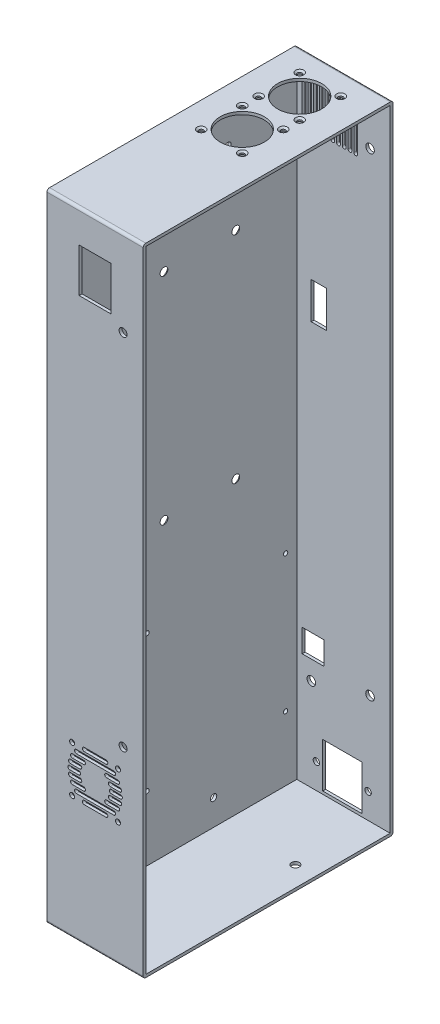
from build123d import *

# Parameters (mm, degrees)
SKETCH1_W                                         = 174
SKETCH1_H                                         = 443
BOSS_EXTRUDE1_DEPTH                               = 2
SKETCH2_W                                         = 174
SKETCH2_H                                         = 443
SKETCH2_W_2                                       = 170
SKETCH2_H_2                                       = 439
BOSS_EXTRUDE2_DEPTH                               = 65
FILLET1_R                                         = 1.8
SKETCH4_R                                         = 1.75
SKETCH4_R_2                                       = 2.75
SKETCH4_W                                         = 22.15
SKETCH4_H                                         = 30.5
CUT_EXTRUDE1_DEPTH                                = 5
SKETCH5_R                                         = 2.25
SKETCH5_R_2                                       = 3
SKETCH5_W                                         = 27.3
SKETCH5_H                                         = 31.1
SKETCH5_W_2                                       = 15.303
SKETCH5_H_2                                       = 16
SKETCH5_W_3                                       = 10.5
SKETCH5_H_3                                       = 25.5
CUT_EXTRUDE2_DEPTH                                = 5
SKETCH11_R                                        = 1.5
SKETCH11_R_2                                      = 2.25
CUT_EXTRUDE4_DEPTH                                = 5
CSK_FOR_M4_FLAT_HEAD_MACHINE_SCREW1_D             = 4.5
CSK_FOR_M4_FLAT_HEAD_MACHINE_SCREW1_DEPTH         = 10
CSK_FOR_M4_FLAT_HEAD_MACHINE_SCREW1_CSINK_D       = 9.4
CSK_FOR_M4_FLAT_HEAD_MACHINE_SCREW1_CSINK_ANGLE   = 90
CSK_FOR_M4_FLAT_HEAD_MACHINE_SCREW1_TIP           = 1.351936393
SKETCH14_R                                        = 15.365
SKETCH14_R_2                                      = 1.5
CUT_EXTRUDE5_DEPTH                                = 10
CSK_FOR_4_FLAT_HEAD_MACHINE_SCREW_100_D           = 3.2639
CSK_FOR_4_FLAT_HEAD_MACHINE_SCREW_100_DEPTH       = 10
CSK_FOR_4_FLAT_HEAD_MACHINE_SCREW_100_CSINK_D     = 5.715
CSK_FOR_4_FLAT_HEAD_MACHINE_SCREW_100_CSINK_ANGLE = 100
CSK_FOR_4_FLAT_HEAD_MACHINE_SCREW_100_TIP         = 0.980574487
SKETCH17_R                                        = 2.75
CUT_EXTRUDE6_DEPTH                                = 10


with BuildPart() as part:
    # Sketch1 → Boss-Extrude1 (new body)
    with BuildSketch(Plane(origin=(0, 0, 0), x_dir=(0, 0, -1), z_dir=(1, 0, 0))):
        Rectangle(SKETCH1_W, SKETCH1_H)
    extrude(amount=BOSS_EXTRUDE1_DEPTH)

    # Sketch2 → Boss-Extrude2 (add)
    with BuildSketch(Plane(origin=(2, 0, 0), x_dir=(0, 0, -1), z_dir=(1, 0, 0))):
        Rectangle(SKETCH2_W, SKETCH2_H)
        Rectangle(SKETCH2_W_2, SKETCH2_H_2, mode=Mode.SUBTRACT)
    extrude(amount=BOSS_EXTRUDE2_DEPTH)

    # Fillet1
    fillet1_edges = [part.edges().sort_by_distance(p)[0] for p in [
        (33.5, 221.5, 87),
        (33.5, 221.5, -87),
        (33.5, -221.5, -87),
        (33.5, -221.5, 87),
    ]]
    fillet(fillet1_edges, radius=FILLET1_R)

    # Sketch4 → Cut-Extrude1 (cut)
    with BuildSketch(Plane.XY.offset(87)):
        with Locations((17.5, -135.5)):
            Circle(SKETCH4_R)
        with Locations((49.5, -135.5)):
            Circle(SKETCH4_R)
        with Locations((17.5, -103.5)):
            Circle(SKETCH4_R)
        with Locations((49.5, -103.5)):
            Circle(SKETCH4_R)
        with Locations((53, -88.5)):
            Circle(SKETCH4_R_2)
        with Locations((53, 161.5)):
            Circle(SKETCH4_R_2)
        with Locations((33.5, 183.75)):
            Rectangle(SKETCH4_W, SKETCH4_H)
        with BuildLine():
            Line((15.8, -118.2), (22.2, -118.2))
            ThreePointArc((22.2, -118.2), (23.5, -119.5), (22.2, -120.8))
            Line((22.2, -120.8), (15.8, -120.8))
            ThreePointArc((15.8, -120.8), (14.5, -119.5), (15.8, -118.2))
        make_face()
        with BuildLine():
            Line((16.25790036, -114.2), (22.931651028, -114.2))
            ThreePointArc((22.931651028, -114.2), (24.231651028, -115.5), (22.931651028, -116.8))
            Line((22.931651028, -116.8), (16.25790036, -116.8))
            ThreePointArc((16.25790036, -116.8), (14.95790036, -115.5), (16.25790036, -114.2))
        make_face()
        with BuildLine():
            Line((17.711079834, -110.2), (25.519398519, -110.2))
            ThreePointArc((25.519398519, -110.2), (26.819398519, -111.5), (25.519398519, -112.8))
            Line((25.519398519, -112.8), (17.711079834, -112.8))
            ThreePointArc((17.711079834, -112.8), (16.411079834, -111.5), (17.711079834, -110.2))
        make_face()
        with BuildLine():
            Line((20.488850935, -106.2), (46.511149065, -106.2))
            ThreePointArc((46.511149065, -106.2), (47.811149065, -107.5), (46.511149065, -108.8))
            Line((46.511149065, -108.8), (20.488850935, -108.8))
            ThreePointArc((20.488850935, -108.8), (19.188850935, -107.5), (20.488850935, -106.2))
        make_face()
        with BuildLine():
            Line((25.930984212, -102.2), (41.069015788, -102.2))
            ThreePointArc((41.069015788, -102.2), (42.369015788, -103.5), (41.069015788, -104.8))
            Line((41.069015788, -104.8), (25.930984212, -104.8))
            ThreePointArc((25.930984212, -104.8), (24.630984212, -103.5), (25.930984212, -102.2))
        make_face()
        with BuildLine():
            Line((16.25790036, -122.2), (22.931651028, -122.2))
            ThreePointArc((22.931651028, -122.2), (24.231651028, -123.5), (22.931651028, -124.8))
            Line((22.931651028, -124.8), (16.25790036, -124.8))
            ThreePointArc((16.25790036, -124.8), (14.95790036, -123.5), (16.25790036, -122.2))
        make_face()
        with BuildLine():
            Line((17.711079834, -126.2), (25.519398519, -126.2))
            ThreePointArc((25.519398519, -126.2), (26.819398519, -127.5), (25.519398519, -128.8))
            Line((25.519398519, -128.8), (17.711079834, -128.8))
            ThreePointArc((17.711079834, -128.8), (16.411079834, -127.5), (17.711079834, -126.2))
        make_face()
        with BuildLine():
            Line((41.480601481, -110.2), (49.288920166, -110.2))
            ThreePointArc((49.288920166, -110.2), (50.588920166, -111.5), (49.288920166, -112.8))
            Line((49.288920166, -112.8), (41.480601481, -112.8))
            ThreePointArc((41.480601481, -112.8), (40.180601481, -111.5), (41.480601481, -110.2))
        make_face()
        with BuildLine():
            Line((44.068348972, -114.2), (50.74209964, -114.2))
            ThreePointArc((50.74209964, -114.2), (52.04209964, -115.5), (50.74209964, -116.8))
            Line((50.74209964, -116.8), (44.068348972, -116.8))
            ThreePointArc((44.068348972, -116.8), (42.768348972, -115.5), (44.068348972, -114.2))
        make_face()
        with BuildLine():
            Line((44.8, -118.2), (51.2, -118.2))
            ThreePointArc((51.2, -118.2), (52.5, -119.5), (51.2, -120.8))
            Line((51.2, -120.8), (44.8, -120.8))
            ThreePointArc((44.8, -120.8), (43.5, -119.5), (44.8, -118.2))
        make_face()
        with BuildLine():
            Line((44.068348972, -122.2), (50.74209964, -122.2))
            ThreePointArc((50.74209964, -122.2), (52.04209964, -123.5), (50.74209964, -124.8))
            Line((50.74209964, -124.8), (44.068348972, -124.8))
            ThreePointArc((44.068348972, -124.8), (42.768348972, -123.5), (44.068348972, -122.2))
        make_face()
        with BuildLine():
            Line((41.480601481, -126.2), (49.288920166, -126.2))
            ThreePointArc((49.288920166, -126.2), (50.588920166, -127.5), (49.288920166, -128.8))
            Line((49.288920166, -128.8), (41.480601481, -128.8))
            ThreePointArc((41.480601481, -128.8), (40.180601481, -127.5), (41.480601481, -126.2))
        make_face()
        with BuildLine():
            Line((20.488850935, -130.2), (46.511149065, -130.2))
            ThreePointArc((46.511149065, -130.2), (47.811149065, -131.5), (46.511149065, -132.8))
            Line((46.511149065, -132.8), (20.488850935, -132.8))
            ThreePointArc((20.488850935, -132.8), (19.188850935, -131.5), (20.488850935, -130.2))
        make_face()
        with BuildLine():
            Line((25.930984212, -134.2), (41.069015788, -134.2))
            ThreePointArc((41.069015788, -134.2), (42.369015788, -135.5), (41.069015788, -136.8))
            Line((41.069015788, -136.8), (25.930984212, -136.8))
            ThreePointArc((25.930984212, -136.8), (24.630984212, -135.5), (25.930984212, -134.2))
        make_face()
    extrude(amount=-CUT_EXTRUDE1_DEPTH, mode=Mode.SUBTRACT)

    # Sketch5 → Cut-Extrude2 (cut)
    with BuildSketch(Plane(origin=(0, 0, -87), x_dir=(-1, 0, 0), z_dir=(0, 0, -1))):
        with Locations(Location((-51.65, -201.95, 0), (0, 0, 90))):  # turned: the seam where the file's is
            Circle(SKETCH5_R)
        with Locations(Location((-15.65, -201.95, 0), (0, 0, 90))):  # turned: the seam where the file's is
            Circle(SKETCH5_R)
        with Locations(Location((-12.096, -155.07, 0), (0, 0, 90))):  # turned: the seam where the file's is
            Circle(SKETCH5_R_2)
        with Locations(Location((-53, 186.5, 0), (0, 0, 90))):  # turned: the seam where the file's is
            Circle(SKETCH5_R_2)
        with Locations(Location((-53, -143.5, 0), (0, 0, 90))):  # turned: the seam where the file's is
            Circle(SKETCH5_R_2)
        with Locations((-33.65, -201.95)):
            Rectangle(SKETCH5_W, SKETCH5_H)
        with Locations((-13.4295, -133.89)):
            Rectangle(SKETCH5_W_2, SKETCH5_H_2)
        with Locations((-17.25, 74.25)):
            Rectangle(SKETCH5_W_3, SKETCH5_H_3)
        with BuildLine():
            Line((-41.7, 213.5), (-41.7, 178.5))
            ThreePointArc((-41.7, 178.5), (-43, 177.2), (-44.3, 178.5))
            Line((-44.3, 178.5), (-44.3, 213.5))
            ThreePointArc((-44.3, 213.5), (-43, 214.8), (-41.7, 213.5))
        make_face()
        with BuildLine():
            Line((-33.7, 213.5), (-33.7, 178.5))
            ThreePointArc((-33.7, 178.5), (-35, 177.2), (-36.3, 178.5))
            Line((-36.3, 178.5), (-36.3, 213.5))
            ThreePointArc((-36.3, 213.5), (-35, 214.8), (-33.7, 213.5))
        make_face()
        with BuildLine():
            Line((-37.7, 213.5), (-37.7, 178.5))
            ThreePointArc((-37.7, 178.5), (-39, 177.2), (-40.3, 178.5))
            Line((-40.3, 178.5), (-40.3, 213.5))
            ThreePointArc((-40.3, 213.5), (-39, 214.8), (-37.7, 213.5))
        make_face()
        with BuildLine():
            Line((-29.7, 213.5), (-29.7, 178.5))
            ThreePointArc((-29.7, 178.5), (-31, 177.2), (-32.3, 178.5))
            Line((-32.3, 178.5), (-32.3, 213.5))
            ThreePointArc((-32.3, 213.5), (-31, 214.8), (-29.7, 213.5))
        make_face()
        with BuildLine():
            Line((-25.7, 213.5), (-25.7, 178.5))
            ThreePointArc((-25.7, 178.5), (-27, 177.2), (-28.3, 178.5))
            Line((-28.3, 178.5), (-28.3, 213.5))
            ThreePointArc((-28.3, 213.5), (-27, 214.8), (-25.7, 213.5))
        make_face()
        with BuildLine():
            Line((-21.7, 213.5), (-21.7, 178.5))
            ThreePointArc((-21.7, 178.5), (-23, 177.2), (-24.3, 178.5))
            Line((-24.3, 178.5), (-24.3, 213.5))
            ThreePointArc((-24.3, 213.5), (-23, 214.8), (-21.7, 213.5))
        make_face()
        with BuildLine():
            Line((-13.7, 213.5), (-13.7, 178.5))
            ThreePointArc((-13.7, 178.5), (-15, 177.2), (-16.3, 178.5))
            Line((-16.3, 178.5), (-16.3, 213.5))
            ThreePointArc((-16.3, 213.5), (-15, 214.8), (-13.7, 213.5))
        make_face()
        with BuildLine():
            Line((-5.7, 213.5), (-5.7, 178.5))
            ThreePointArc((-5.7, 178.5), (-7, 177.2), (-8.3, 178.5))
            Line((-8.3, 178.5), (-8.3, 213.5))
            ThreePointArc((-8.3, 213.5), (-7, 214.8), (-5.7, 213.5))
        make_face()
        with BuildLine():
            Line((-17.7, 213.5), (-17.7, 178.5))
            ThreePointArc((-17.7, 178.5), (-19, 177.2), (-20.3, 178.5))
            Line((-20.3, 178.5), (-20.3, 213.5))
            ThreePointArc((-20.3, 213.5), (-19, 214.8), (-17.7, 213.5))
        make_face()
        with BuildLine():
            Line((-9.7, 213.5), (-9.7, 178.5))
            ThreePointArc((-9.7, 178.5), (-11, 177.2), (-12.3, 178.5))
            Line((-12.3, 178.5), (-12.3, 213.5))
            ThreePointArc((-12.3, 213.5), (-11, 214.8), (-9.7, 213.5))
        make_face()
    extrude(amount=-CUT_EXTRUDE2_DEPTH, mode=Mode.SUBTRACT)

    # Sketch11 → Cut-Extrude4 (cut)
    with BuildSketch(Plane(origin=(2, 0, 0), x_dir=(0, 0, -1), z_dir=(1, 0, 0))):
        with Locations((-19.33, -79.31)):
            Circle(SKETCH11_R)
        with Locations((77.19, -79.31)):
            Circle(SKETCH11_R)
        with Locations((-19.33, -174.56)):
            Circle(SKETCH11_R)
        with Locations((77.19, -174.56)):
            Circle(SKETCH11_R)
        with Locations((-7.5, 133)):
            Circle(SKETCH11_R)
        with Locations((42.5, 133)):
            Circle(SKETCH11_R)
        with Locations((42.5, -17)):
            Circle(SKETCH11_R)
        with Locations((-7.5, -17)):
            Circle(SKETCH11_R)
        with Locations((27, -201.5)):
            Circle(SKETCH11_R_2)
        with Locations((37, 186.5)):
            Circle(SKETCH11_R_2)
    extrude(amount=-CUT_EXTRUDE4_DEPTH, mode=Mode.SUBTRACT)

    # CSK for M4 Flat Head Machine Screw1
    with Locations(Plane.ZY):
        with Locations((-42.5, 133), (7.5, 133), (7.5, -17), (-42.5, -17)):
            CounterSinkHole(CSK_FOR_M4_FLAT_HEAD_MACHINE_SCREW1_D / 2, CSK_FOR_M4_FLAT_HEAD_MACHINE_SCREW1_CSINK_D / 2, depth=CSK_FOR_M4_FLAT_HEAD_MACHINE_SCREW1_DEPTH, counter_sink_angle=CSK_FOR_M4_FLAT_HEAD_MACHINE_SCREW1_CSINK_ANGLE)
            with Locations((0, 0, -(CSK_FOR_M4_FLAT_HEAD_MACHINE_SCREW1_DEPTH + CSK_FOR_M4_FLAT_HEAD_MACHINE_SCREW1_TIP / 2))):  # 118° drill point
                Cone(0, CSK_FOR_M4_FLAT_HEAD_MACHINE_SCREW1_D / 2, CSK_FOR_M4_FLAT_HEAD_MACHINE_SCREW1_TIP, mode=Mode.SUBTRACT)

    # Sketch14 → Cut-Extrude5 (cut)
    with BuildSketch(Plane(origin=(0, 221.5, 0), x_dir=(1, 0, 0), z_dir=(0, 1, 0))):
        with Locations(Location((32, 57, 0), (0, 0, 270))):  # turned: the seam where the file's is
            Circle(SKETCH14_R)
        with Locations(Location((17.71, 71.29, 0), (0, 0, 270))):  # turned: the seam where the file's is
            Circle(SKETCH14_R_2)
        with Locations(Location((46.29, 71.29, 0), (0, 0, 270))):  # turned: the seam where the file's is
            Circle(SKETCH14_R_2)
        with Locations(Location((46.29, 42.71, 0), (0, 0, 270))):  # turned: the seam where the file's is
            Circle(SKETCH14_R_2)
        with Locations(Location((17.71, 42.71, 0), (0, 0, 270))):  # turned: the seam where the file's is
            Circle(SKETCH14_R_2)
        with Locations(Location((32, 17, 0), (0, 0, 270))):  # turned: the seam where the file's is
            Circle(SKETCH14_R)
        with Locations(Location((17.71, 31.29, 0), (0, 0, 270))):  # turned: the seam where the file's is
            Circle(SKETCH14_R_2)
        with Locations(Location((46.29, 31.29, 0), (0, 0, 270))):  # turned: the seam where the file's is
            Circle(SKETCH14_R_2)
        with Locations(Location((46.29, 2.71, 0), (0, 0, 270))):  # turned: the seam where the file's is
            Circle(SKETCH14_R_2)
        with Locations(Location((17.71, 2.71, 0), (0, 0, 270))):  # turned: the seam where the file's is
            Circle(SKETCH14_R_2)
    extrude(amount=-CUT_EXTRUDE5_DEPTH, mode=Mode.SUBTRACT)

    # CSK for #4 Flat Head Machine Screw (100)1
    with Locations(Plane(origin=(0, 221.5, 0), x_dir=(-1, 0, 0), z_dir=(0, 1, 0))):
        with Locations((-17.71, -71.29), (-17.71, -42.71), (-46.29, -42.71), (-46.29, -71.29), (-17.71, -31.29), (-46.29, -31.29), (-46.29, -2.71), (-17.71, -2.71)):
            CounterSinkHole(CSK_FOR_4_FLAT_HEAD_MACHINE_SCREW_100_D / 2, CSK_FOR_4_FLAT_HEAD_MACHINE_SCREW_100_CSINK_D / 2, depth=CSK_FOR_4_FLAT_HEAD_MACHINE_SCREW_100_DEPTH, counter_sink_angle=CSK_FOR_4_FLAT_HEAD_MACHINE_SCREW_100_CSINK_ANGLE)
            with Locations((0, 0, -(CSK_FOR_4_FLAT_HEAD_MACHINE_SCREW_100_DEPTH + CSK_FOR_4_FLAT_HEAD_MACHINE_SCREW_100_TIP / 2))):  # 118° drill point
                Cone(0, CSK_FOR_4_FLAT_HEAD_MACHINE_SCREW_100_D / 2, CSK_FOR_4_FLAT_HEAD_MACHINE_SCREW_100_TIP, mode=Mode.SUBTRACT)

    # Sketch17 → Cut-Extrude6 (cut)
    with BuildSketch(Plane.XZ.offset(221.5)):
        with Locations(Location((53, -33, 0), (0, 0, 270))):  # turned: the seam where the file's is
            Circle(SKETCH17_R)
    extrude(amount=-CUT_EXTRUDE6_DEPTH, mode=Mode.SUBTRACT)


solid = part.part
